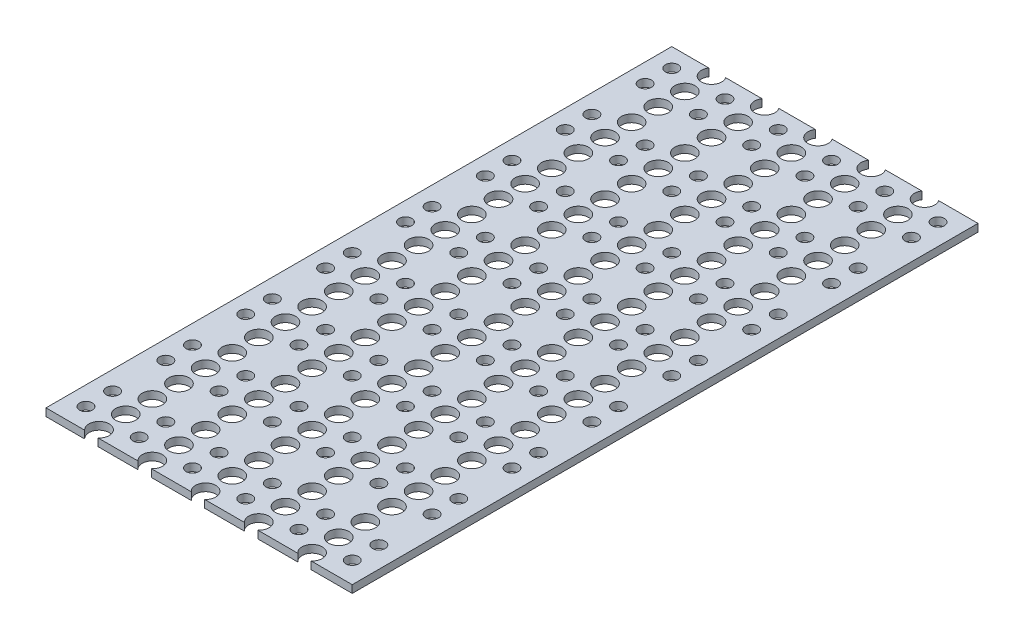
from build123d import *

# Parameters (mm, degrees)
SKETCH1_W           = 241.5
SKETCH1_H           = 493.5
BOSS_EXTRUDE1_DEPTH = 6
SKETCH2_R           = 5
CUT_EXTRUDE1_DEPTH  = 7
SKETCH3_R           = 8
CUT_EXTRUDE2_DEPTH  = 7


with BuildPart() as part:
    # Sketch1 → Boss-Extrude1 (new body)
    with BuildSketch(Plane(origin=(0, 0, 0), x_dir=(1, 0, 0), z_dir=(0, 1, 0))):
        Rectangle(SKETCH1_W, SKETCH1_H)
    extrude(amount=BOSS_EXTRUDE1_DEPTH)

    # Sketch2 → Cut-Extrude1 (cut, through all)
    with BuildSketch(Plane(origin=(0, 6, 0), x_dir=(1, 0, 0), z_dir=(0, 1, 0))):
        with Locations((-105.9, 231.895)):
            Circle(SKETCH2_R)
        with Locations((-63.9, 231.895)):
            Circle(SKETCH2_R)
        with Locations((-21.9, 231.895)):
            Circle(SKETCH2_R)
        with Locations((20.1, 231.895)):
            Circle(SKETCH2_R)
        with Locations((62.1, 231.895)):
            Circle(SKETCH2_R)
        with Locations((-105.9, 210.895)):
            Circle(SKETCH2_R)
        with Locations((-63.9, 210.895)):
            Circle(SKETCH2_R)
        with Locations((-21.9, 210.895)):
            Circle(SKETCH2_R)
        with Locations((20.1, 210.895)):
            Circle(SKETCH2_R)
        with Locations((62.1, 210.895)):
            Circle(SKETCH2_R)
        with Locations((-105.9, 168.895)):
            Circle(SKETCH2_R)
        with Locations((-63.9, 168.895)):
            Circle(SKETCH2_R)
        with Locations((-21.9, 168.895)):
            Circle(SKETCH2_R)
        with Locations((20.1, 168.895)):
            Circle(SKETCH2_R)
        with Locations((62.1, 168.895)):
            Circle(SKETCH2_R)
        with Locations((-105.9, 147.895)):
            Circle(SKETCH2_R)
        with Locations((-63.9, 147.895)):
            Circle(SKETCH2_R)
        with Locations((-21.9, 147.895)):
            Circle(SKETCH2_R)
        with Locations((20.1, 147.895)):
            Circle(SKETCH2_R)
        with Locations((62.1, 147.895)):
            Circle(SKETCH2_R)
        with Locations((-105.9, 105.895)):
            Circle(SKETCH2_R)
        with Locations((-63.9, 105.895)):
            Circle(SKETCH2_R)
        with Locations((-21.9, 105.895)):
            Circle(SKETCH2_R)
        with Locations((20.1, 105.895)):
            Circle(SKETCH2_R)
        with Locations((62.1, 105.895)):
            Circle(SKETCH2_R)
        with Locations((-105.9, 84.895)):
            Circle(SKETCH2_R)
        with Locations((-63.9, 84.895)):
            Circle(SKETCH2_R)
        with Locations((-21.9, 84.895)):
            Circle(SKETCH2_R)
        with Locations((20.1, 84.895)):
            Circle(SKETCH2_R)
        with Locations((62.1, 84.895)):
            Circle(SKETCH2_R)
        with Locations((-105.9, 42.895)):
            Circle(SKETCH2_R)
        with Locations((-63.9, 42.895)):
            Circle(SKETCH2_R)
        with Locations((-21.9, 42.895)):
            Circle(SKETCH2_R)
        with Locations((20.1, 42.895)):
            Circle(SKETCH2_R)
        with Locations((62.1, 42.895)):
            Circle(SKETCH2_R)
        with Locations((-105.9, 21.895)):
            Circle(SKETCH2_R)
        with Locations((-63.9, 21.895)):
            Circle(SKETCH2_R)
        with Locations((-21.9, 21.895)):
            Circle(SKETCH2_R)
        with Locations((20.1, 21.895)):
            Circle(SKETCH2_R)
        with Locations((62.1, 21.895)):
            Circle(SKETCH2_R)
        with Locations((104.1, 231.895)):
            Circle(SKETCH2_R)
        with Locations((104.1, 210.895)):
            Circle(SKETCH2_R)
        with Locations((104.1, 168.895)):
            Circle(SKETCH2_R)
        with Locations((104.1, 147.895)):
            Circle(SKETCH2_R)
        with Locations((104.1, 105.895)):
            Circle(SKETCH2_R)
        with Locations((104.1, 84.895)):
            Circle(SKETCH2_R)
        with Locations((104.1, 42.895)):
            Circle(SKETCH2_R)
        with Locations((104.1, 21.895)):
            Circle(SKETCH2_R)
        with Locations((-105.9, -20.105)):
            Circle(SKETCH2_R)
        with Locations((-63.9, -20.105)):
            Circle(SKETCH2_R)
        with Locations((-21.9, -20.105)):
            Circle(SKETCH2_R)
        with Locations((20.1, -20.105)):
            Circle(SKETCH2_R)
        with Locations((62.1, -20.105)):
            Circle(SKETCH2_R)
        with Locations((104.1, -20.105)):
            Circle(SKETCH2_R)
        with Locations((-105.9, -41.105)):
            Circle(SKETCH2_R)
        with Locations((-63.9, -41.105)):
            Circle(SKETCH2_R)
        with Locations((-21.9, -41.105)):
            Circle(SKETCH2_R)
        with Locations((20.1, -41.105)):
            Circle(SKETCH2_R)
        with Locations((62.1, -41.105)):
            Circle(SKETCH2_R)
        with Locations((104.1, -41.105)):
            Circle(SKETCH2_R)
        with Locations((-105.9, -83.105)):
            Circle(SKETCH2_R)
        with Locations((-63.9, -83.105)):
            Circle(SKETCH2_R)
        with Locations((-21.9, -83.105)):
            Circle(SKETCH2_R)
        with Locations((20.1, -83.105)):
            Circle(SKETCH2_R)
        with Locations((62.1, -83.105)):
            Circle(SKETCH2_R)
        with Locations((104.1, -83.105)):
            Circle(SKETCH2_R)
        with Locations((-105.9, -104.105)):
            Circle(SKETCH2_R)
        with Locations((-63.9, -104.105)):
            Circle(SKETCH2_R)
        with Locations((-21.9, -104.105)):
            Circle(SKETCH2_R)
        with Locations((20.1, -104.105)):
            Circle(SKETCH2_R)
        with Locations((62.1, -104.105)):
            Circle(SKETCH2_R)
        with Locations((104.1, -104.105)):
            Circle(SKETCH2_R)
        with Locations((-105.9, -146.105)):
            Circle(SKETCH2_R)
        with Locations((-63.9, -146.105)):
            Circle(SKETCH2_R)
        with Locations((-21.9, -146.105)):
            Circle(SKETCH2_R)
        with Locations((20.1, -146.105)):
            Circle(SKETCH2_R)
        with Locations((62.1, -146.105)):
            Circle(SKETCH2_R)
        with Locations((104.1, -146.105)):
            Circle(SKETCH2_R)
        with Locations((-105.9, -167.105)):
            Circle(SKETCH2_R)
        with Locations((-63.9, -167.105)):
            Circle(SKETCH2_R)
        with Locations((-21.9, -167.105)):
            Circle(SKETCH2_R)
        with Locations((20.1, -167.105)):
            Circle(SKETCH2_R)
        with Locations((62.1, -167.105)):
            Circle(SKETCH2_R)
        with Locations((104.1, -167.105)):
            Circle(SKETCH2_R)
        with Locations((-105.9, -209.105)):
            Circle(SKETCH2_R)
        with Locations((-63.9, -209.105)):
            Circle(SKETCH2_R)
        with Locations((-21.9, -209.105)):
            Circle(SKETCH2_R)
        with Locations((20.1, -209.105)):
            Circle(SKETCH2_R)
        with Locations((62.1, -209.105)):
            Circle(SKETCH2_R)
        with Locations((104.1, -209.105)):
            Circle(SKETCH2_R)
        with Locations((-105.9, -230.105)):
            Circle(SKETCH2_R)
        with Locations((-63.9, -230.105)):
            Circle(SKETCH2_R)
        with Locations((-21.9, -230.105)):
            Circle(SKETCH2_R)
        with Locations((20.1, -230.105)):
            Circle(SKETCH2_R)
        with Locations((62.1, -230.105)):
            Circle(SKETCH2_R)
        with Locations((104.1, -230.105)):
            Circle(SKETCH2_R)
    extrude(amount=-CUT_EXTRUDE1_DEPTH, mode=Mode.SUBTRACT)

    # Sketch3 → Cut-Extrude2 (cut, through all)
    with BuildSketch(Plane(origin=(0, 6, 0), x_dir=(1, 0, 0), z_dir=(0, 1, 0))):
        with Locations((-84.9, 242.25)):
            Circle(SKETCH3_R)
        with Locations((-42.9, 242.25)):
            Circle(SKETCH3_R)
        with Locations((-0.9, 242.25)):
            Circle(SKETCH3_R)
        with Locations((41.1, 242.25)):
            Circle(SKETCH3_R)
        with Locations((83.1, 242.25)):
            Circle(SKETCH3_R)
        with Locations((-42.9, 221.25)):
            Circle(SKETCH3_R)
        with Locations((-0.9, 221.25)):
            Circle(SKETCH3_R)
        with Locations((41.1, 221.25)):
            Circle(SKETCH3_R)
        with Locations((83.1, 221.25)):
            Circle(SKETCH3_R)
        with Locations((-42.9, 200.25)):
            Circle(SKETCH3_R)
        with Locations((-0.9, 200.25)):
            Circle(SKETCH3_R)
        with Locations((41.1, 200.25)):
            Circle(SKETCH3_R)
        with Locations((83.1, 200.25)):
            Circle(SKETCH3_R)
        with Locations((-42.9, 179.25)):
            Circle(SKETCH3_R)
        with Locations((-0.9, 179.25)):
            Circle(SKETCH3_R)
        with Locations((41.1, 179.25)):
            Circle(SKETCH3_R)
        with Locations((83.1, 179.25)):
            Circle(SKETCH3_R)
        with Locations((-42.9, 158.25)):
            Circle(SKETCH3_R)
        with Locations((-0.9, 158.25)):
            Circle(SKETCH3_R)
        with Locations((41.1, 158.25)):
            Circle(SKETCH3_R)
        with Locations((83.1, 158.25)):
            Circle(SKETCH3_R)
        with Locations((-42.9, 137.25)):
            Circle(SKETCH3_R)
        with Locations((-0.9, 137.25)):
            Circle(SKETCH3_R)
        with Locations((41.1, 137.25)):
            Circle(SKETCH3_R)
        with Locations((83.1, 137.25)):
            Circle(SKETCH3_R)
        with Locations((-42.9, 116.25)):
            Circle(SKETCH3_R)
        with Locations((-0.9, 116.25)):
            Circle(SKETCH3_R)
        with Locations((41.1, 116.25)):
            Circle(SKETCH3_R)
        with Locations((83.1, 116.25)):
            Circle(SKETCH3_R)
        with Locations((-42.9, 95.25)):
            Circle(SKETCH3_R)
        with Locations((-0.9, 95.25)):
            Circle(SKETCH3_R)
        with Locations((41.1, 95.25)):
            Circle(SKETCH3_R)
        with Locations((83.1, 95.25)):
            Circle(SKETCH3_R)
        with Locations((-42.9, 74.25)):
            Circle(SKETCH3_R)
        with Locations((-0.9, 74.25)):
            Circle(SKETCH3_R)
        with Locations((41.1, 74.25)):
            Circle(SKETCH3_R)
        with Locations((83.1, 74.25)):
            Circle(SKETCH3_R)
        with Locations((-42.9, 53.25)):
            Circle(SKETCH3_R)
        with Locations((-0.9, 53.25)):
            Circle(SKETCH3_R)
        with Locations((41.1, 53.25)):
            Circle(SKETCH3_R)
        with Locations((83.1, 53.25)):
            Circle(SKETCH3_R)
        with Locations((-42.9, 32.25)):
            Circle(SKETCH3_R)
        with Locations((-0.9, 32.25)):
            Circle(SKETCH3_R)
        with Locations((41.1, 32.25)):
            Circle(SKETCH3_R)
        with Locations((83.1, 32.25)):
            Circle(SKETCH3_R)
        with Locations((-42.9, 11.25)):
            Circle(SKETCH3_R)
        with Locations((-0.9, 11.25)):
            Circle(SKETCH3_R)
        with Locations((41.1, 11.25)):
            Circle(SKETCH3_R)
        with Locations((83.1, 11.25)):
            Circle(SKETCH3_R)
        with Locations((-42.9, -9.75)):
            Circle(SKETCH3_R)
        with Locations((-0.9, -9.75)):
            Circle(SKETCH3_R)
        with Locations((41.1, -9.75)):
            Circle(SKETCH3_R)
        with Locations((83.1, -9.75)):
            Circle(SKETCH3_R)
        with Locations((-42.9, -30.75)):
            Circle(SKETCH3_R)
        with Locations((-0.9, -30.75)):
            Circle(SKETCH3_R)
        with Locations((41.1, -30.75)):
            Circle(SKETCH3_R)
        with Locations((83.1, -30.75)):
            Circle(SKETCH3_R)
        with Locations((-42.9, -51.75)):
            Circle(SKETCH3_R)
        with Locations((-0.9, -51.75)):
            Circle(SKETCH3_R)
        with Locations((41.1, -51.75)):
            Circle(SKETCH3_R)
        with Locations((83.1, -51.75)):
            Circle(SKETCH3_R)
        with Locations((-42.9, -72.75)):
            Circle(SKETCH3_R)
        with Locations((-0.9, -72.75)):
            Circle(SKETCH3_R)
        with Locations((41.1, -72.75)):
            Circle(SKETCH3_R)
        with Locations((83.1, -72.75)):
            Circle(SKETCH3_R)
        with Locations((-42.9, -93.75)):
            Circle(SKETCH3_R)
        with Locations((-0.9, -93.75)):
            Circle(SKETCH3_R)
        with Locations((41.1, -93.75)):
            Circle(SKETCH3_R)
        with Locations((83.1, -93.75)):
            Circle(SKETCH3_R)
        with Locations((-42.9, -114.75)):
            Circle(SKETCH3_R)
        with Locations((-0.9, -114.75)):
            Circle(SKETCH3_R)
        with Locations((41.1, -114.75)):
            Circle(SKETCH3_R)
        with Locations((83.1, -114.75)):
            Circle(SKETCH3_R)
        with Locations((-42.9, -135.75)):
            Circle(SKETCH3_R)
        with Locations((-0.9, -135.75)):
            Circle(SKETCH3_R)
        with Locations((41.1, -135.75)):
            Circle(SKETCH3_R)
        with Locations((83.1, -135.75)):
            Circle(SKETCH3_R)
        with Locations((-42.9, -156.75)):
            Circle(SKETCH3_R)
        with Locations((-0.9, -156.75)):
            Circle(SKETCH3_R)
        with Locations((41.1, -156.75)):
            Circle(SKETCH3_R)
        with Locations((83.1, -156.75)):
            Circle(SKETCH3_R)
        with Locations((-42.9, -177.75)):
            Circle(SKETCH3_R)
        with Locations((-0.9, -177.75)):
            Circle(SKETCH3_R)
        with Locations((41.1, -177.75)):
            Circle(SKETCH3_R)
        with Locations((83.1, -177.75)):
            Circle(SKETCH3_R)
        with Locations((-42.9, -198.75)):
            Circle(SKETCH3_R)
        with Locations((-0.9, -198.75)):
            Circle(SKETCH3_R)
        with Locations((41.1, -198.75)):
            Circle(SKETCH3_R)
        with Locations((83.1, -198.75)):
            Circle(SKETCH3_R)
        with Locations((-42.9, -219.75)):
            Circle(SKETCH3_R)
        with Locations((-0.9, -219.75)):
            Circle(SKETCH3_R)
        with Locations((41.1, -219.75)):
            Circle(SKETCH3_R)
        with Locations((83.1, -219.75)):
            Circle(SKETCH3_R)
        with Locations((-42.9, -240.75)):
            Circle(SKETCH3_R)
        with Locations((-0.9, -240.75)):
            Circle(SKETCH3_R)
        with Locations((41.1, -240.75)):
            Circle(SKETCH3_R)
        with Locations((83.1, -240.75)):
            Circle(SKETCH3_R)
        with Locations((-84.9, 221.25)):
            Circle(SKETCH3_R)
        with Locations((-84.9, 200.25)):
            Circle(SKETCH3_R)
        with Locations((-84.9, 179.25)):
            Circle(SKETCH3_R)
        with Locations((-84.9, 158.25)):
            Circle(SKETCH3_R)
        with Locations((-84.9, 137.25)):
            Circle(SKETCH3_R)
        with Locations((-84.9, 116.25)):
            Circle(SKETCH3_R)
        with Locations((-84.9, 95.25)):
            Circle(SKETCH3_R)
        with Locations((-84.9, 74.25)):
            Circle(SKETCH3_R)
        with Locations((-84.9, 53.25)):
            Circle(SKETCH3_R)
        with Locations((-84.9, 32.25)):
            Circle(SKETCH3_R)
        with Locations((-84.9, 11.25)):
            Circle(SKETCH3_R)
        with Locations((-84.9, -9.75)):
            Circle(SKETCH3_R)
        with Locations((-84.9, -30.75)):
            Circle(SKETCH3_R)
        with Locations((-84.9, -51.75)):
            Circle(SKETCH3_R)
        with Locations((-84.9, -72.75)):
            Circle(SKETCH3_R)
        with Locations((-84.9, -93.75)):
            Circle(SKETCH3_R)
        with Locations((-84.9, -114.75)):
            Circle(SKETCH3_R)
        with Locations((-84.9, -135.75)):
            Circle(SKETCH3_R)
        with Locations((-84.9, -156.75)):
            Circle(SKETCH3_R)
        with Locations((-84.9, -177.75)):
            Circle(SKETCH3_R)
        with Locations((-84.9, -198.75)):
            Circle(SKETCH3_R)
        with Locations((-84.9, -219.75)):
            Circle(SKETCH3_R)
        with Locations((-84.9, -240.75)):
            Circle(SKETCH3_R)
    extrude(amount=-CUT_EXTRUDE2_DEPTH, mode=Mode.SUBTRACT)


solid = part.part
